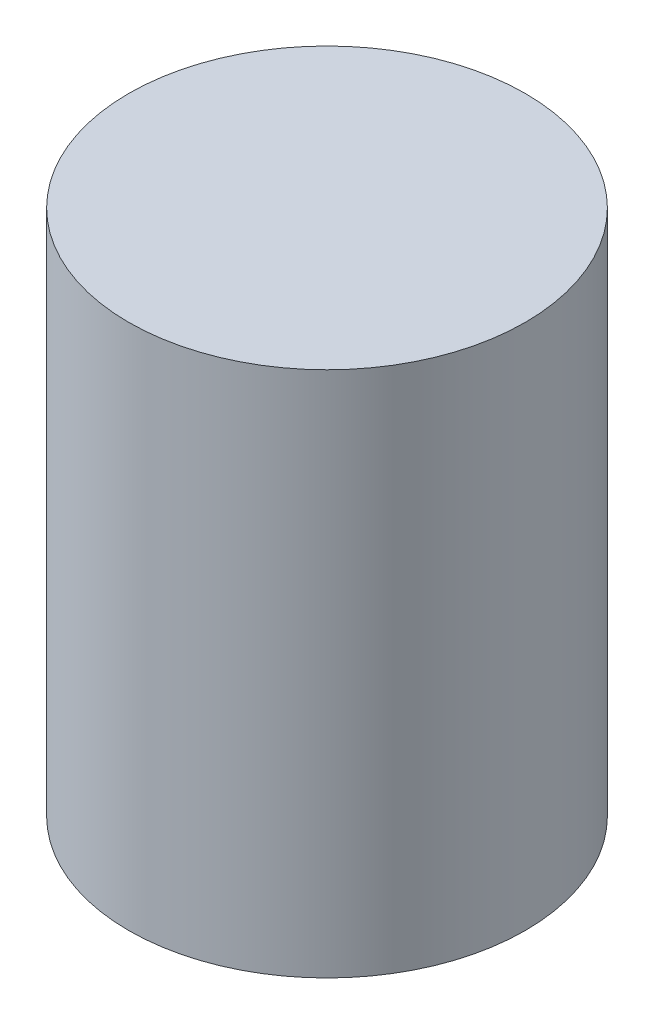
from build123d import *

# Parameters (mm, degrees)
SKETCH1_R           = 99
BOSS_EXTRUDE1_DEPTH = 131.5


with BuildPart() as part:
    # Sketch1 → Boss-Extrude1 (new body, symmetric)
    with BuildSketch(Plane(origin=(0, 0, 0), x_dir=(1, 0, 0), z_dir=(0, 1, 0))):
        Circle(SKETCH1_R)
    extrude(amount=BOSS_EXTRUDE1_DEPTH, both=True)


solid = part.part
